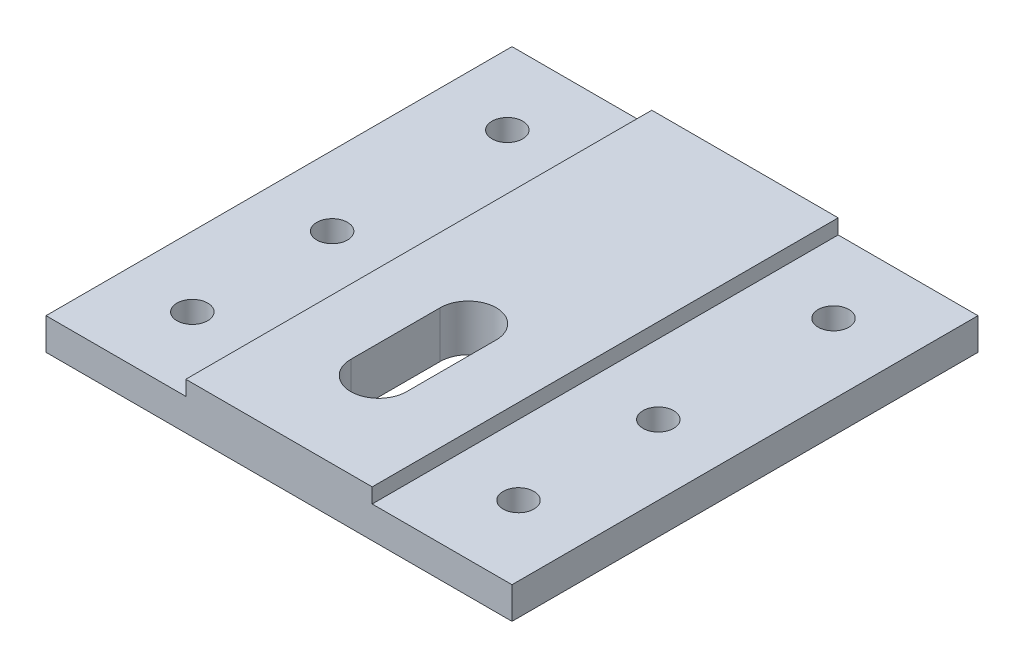
from build123d import *

# Parameters (mm, degrees)
SKETCH2_W              = 127
SKETCH2_H              = 127
BOSS_EXTRUDE1_DEPTH    = 12.7
SKETCH3_W              = 38.1
SKETCH3_H              = 4.04158002
CUT_EXTRUDE2_DEPTH     = 128
F_10_0MM_DOWEL_HOLE1_D = 8.382
CUT_EXTRUDE4_DEPTH     = 13.7


with BuildPart() as part:
    # Sketch2 → Boss-Extrude1 (new body)
    with BuildSketch(Plane(origin=(0, 0, 0), x_dir=(1, 0, 0), z_dir=(0, 1, 0))):
        Rectangle(SKETCH2_W, SKETCH2_H)
    extrude(amount=BOSS_EXTRUDE1_DEPTH)

    # Sketch3 → Cut-Extrude2 (cut, through all)
    with BuildSketch(Plane.XY.offset(63.5)):
        with Locations((-44.45, 10.67920999)):
            Rectangle(SKETCH3_W, SKETCH3_H)
        with Locations((44.45, 10.67920999)):
            Rectangle(SKETCH3_W, SKETCH3_H)
    extrude(amount=-CUT_EXTRUDE2_DEPTH, mode=Mode.SUBTRACT)

    # Ø10.0mm Dowel Hole1 (through all)
    with Locations(Plane(origin=(0, 0, 0), x_dir=(-1, 0, 0), z_dir=(0, -1, 0))):
        with Locations((-44.45, 43.18), (-44.45, -4.572), (-44.45, -42.672), (44.45, 43.18), (44.45, -4.572), (44.45, -42.672)):
            Hole(F_10_0MM_DOWEL_HOLE1_D / 2)

    # Sketch10 → Cut-Extrude4 (cut, through all)
    with BuildSketch(Plane(origin=(0, 0, 0), x_dir=(-1, 0, 0), z_dir=(0, -1, 0))):
        with BuildLine():
            Line((7.62, -11.938), (7.62, -36.322))
            ThreePointArc((7.62, -36.322), (0, -43.942), (-7.62, -36.322))
            Line((-7.62, -36.322), (-7.62, -11.938))
            ThreePointArc((-7.62, -11.938), (0, -4.318), (7.62, -11.938))
        make_face()
    extrude(amount=-CUT_EXTRUDE4_DEPTH, mode=Mode.SUBTRACT)


solid = part.part
